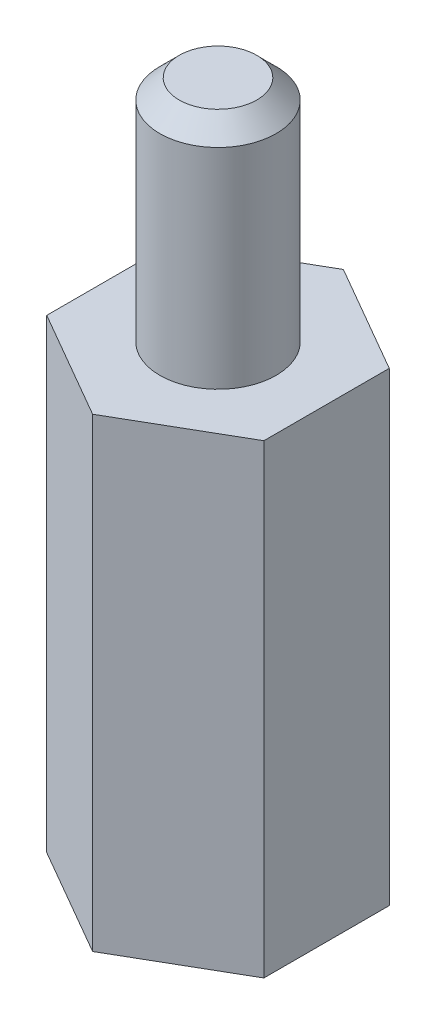
from build123d import *

# Parameters (mm, degrees)
BOSS_EXTRUDE1_DEPTH = 12
SKETCH2_R           = 1.5
BOSS_EXTRUDE2_DEPTH = 5.9
SKETCH3_R           = 1.5
CUT_EXTRUDE1_DEPTH  = 10
CHAMFER1_SIZE       = 0.5


with BuildPart() as part:
    # Sketch1 → Boss-Extrude1 (new body)
    with BuildSketch(Plane(origin=(0, 0, 0), x_dir=(1, 0, 0), z_dir=(0, 1, 0))):
        Polygon((0, -3.233161507), (2.8, -1.616580754), (2.8, 1.616580754), (0, 3.233161507), (-2.8, 1.616580754), (-2.8, -1.616580754), align=None)
    extrude(amount=BOSS_EXTRUDE1_DEPTH)

    # Sketch2 → Boss-Extrude2 (add)
    with BuildSketch(Plane(origin=(0, 12, 0), x_dir=(1, 0, 0), z_dir=(0, 1, 0))):
        Circle(SKETCH2_R)
    extrude(amount=BOSS_EXTRUDE2_DEPTH)

    # Sketch3 → Cut-Extrude1 (cut)
    with BuildSketch(Plane.XZ):
        Circle(SKETCH3_R)
    extrude(amount=-CUT_EXTRUDE1_DEPTH, mode=Mode.SUBTRACT)

    # Chamfer1
    chamfer1_edges = [part.edges().sort_by_distance(p)[0] for p in [
        (-1.5, 17.9, 0),
    ]]
    chamfer(chamfer1_edges, length=CHAMFER1_SIZE)


solid = part.part
